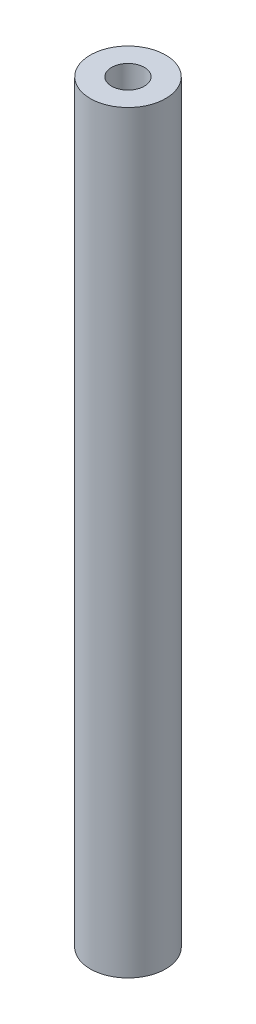
from build123d import *

# Parameters (mm, degrees)
SKETCH_1_R      = 3.5
SKETCH_1_R_2    = 1.52
EXTRUDE_1_DEPTH = 70


with BuildPart() as part:
    # 草图1 → 凸台-拉伸1 (new body)
    with BuildSketch(Plane(origin=(0, 0, 0), x_dir=(1, 0, 0), z_dir=(0, 1, 0))):
        Circle(SKETCH_1_R)
        Circle(SKETCH_1_R_2, mode=Mode.SUBTRACT)
    extrude(amount=EXTRUDE_1_DEPTH)


solid = part.part
